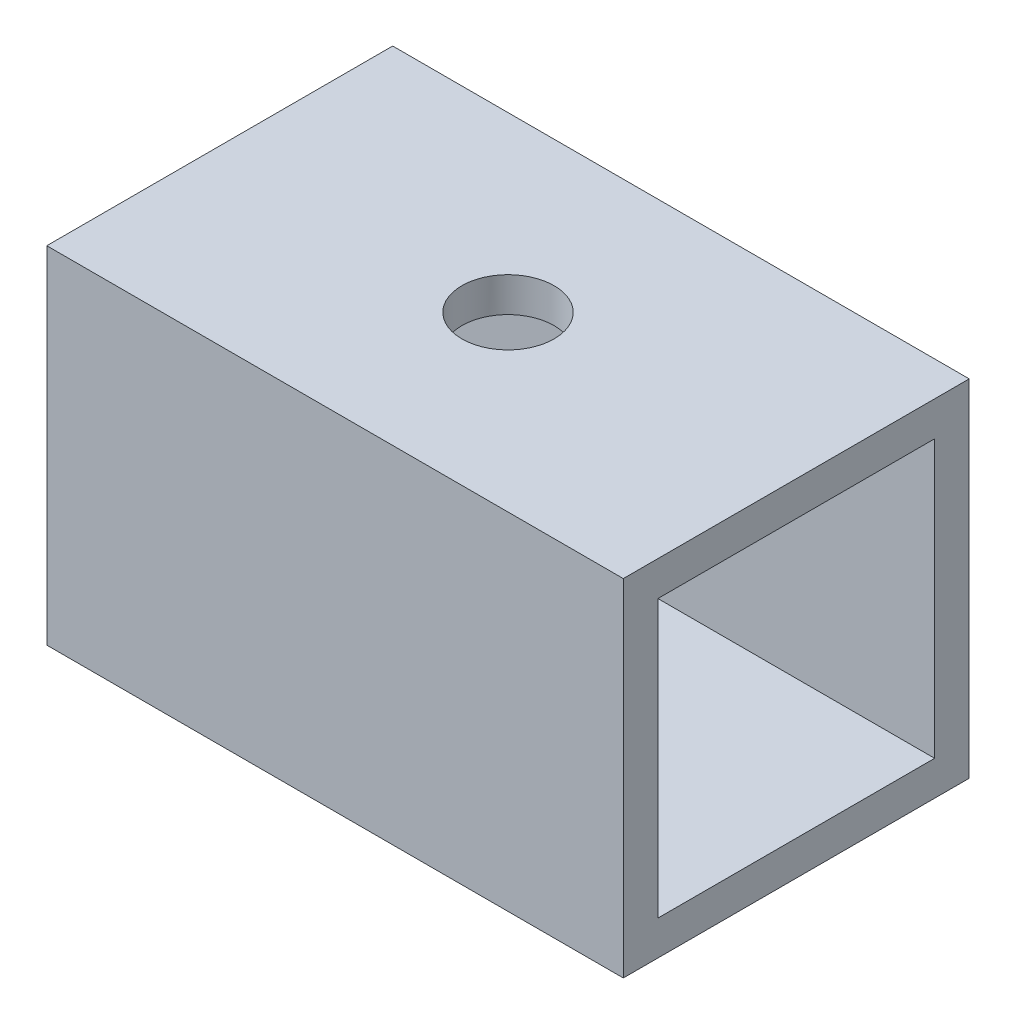
from build123d import *

# Parameters (mm, degrees)
SKETCH1_W           = 15
SKETCH1_H           = 15
SKETCH1_W_2         = 12
SKETCH1_H_2         = 12
BOSS_EXTRUDE1_DEPTH = 25
SKETCH2_R           = 2
CUT_EXTRUDE1_DEPTH  = 16


with BuildPart() as part:
    # Sketch1 → Boss-Extrude1 (new body)
    with BuildSketch(Plane(origin=(0, 0, 0), x_dir=(0, 0, -1), z_dir=(1, 0, 0))):
        Rectangle(SKETCH1_W, SKETCH1_H)
        Rectangle(SKETCH1_W_2, SKETCH1_H_2, mode=Mode.SUBTRACT)
    extrude(amount=BOSS_EXTRUDE1_DEPTH)

    # Sketch2 → Cut-Extrude1 (cut, through all)
    with BuildSketch(Plane(origin=(0, 7.5, 0), x_dir=(1, 0, 0), z_dir=(0, 1, 0))):
        with Locations((12.5, 0)):
            Circle(SKETCH2_R)
    extrude(amount=-CUT_EXTRUDE1_DEPTH, mode=Mode.SUBTRACT)


solid = part.part
